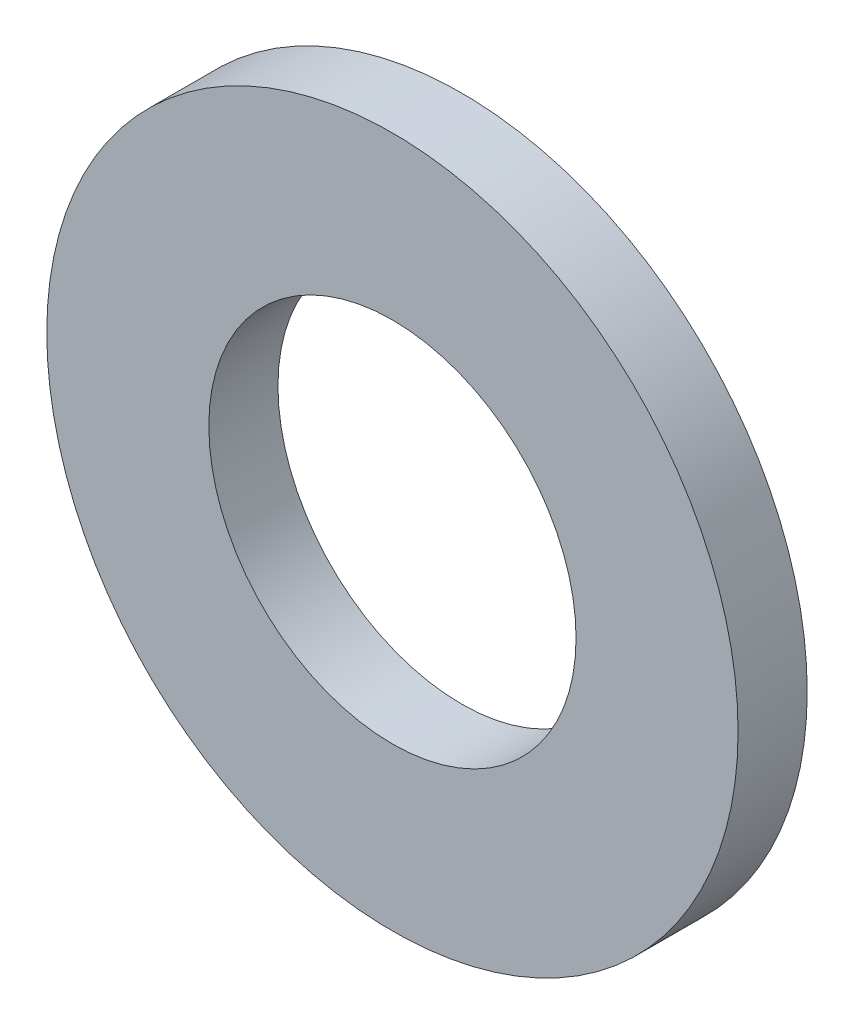
from build123d import *

# Parameters (mm, degrees)
SKETCH1_W = 3.75
SKETCH1_H = 1.6


with BuildPart() as part:
    # Sketch1 → Revolve1 (revolve)
    with BuildSketch(Plane.XZ, mode=Mode.PRIVATE) as revolve1_sk:
        with Locations((6.125, 0.8)):
            Rectangle(SKETCH1_W, SKETCH1_H)
    revolve(revolve1_sk.sketch.rotate(Axis((0, 0, 1.6), (0, 0, -1)), 180), axis=Axis((0, 0, 1.6), (0, 0, -1)))  # turned: the seam where the file's is


solid = part.part
